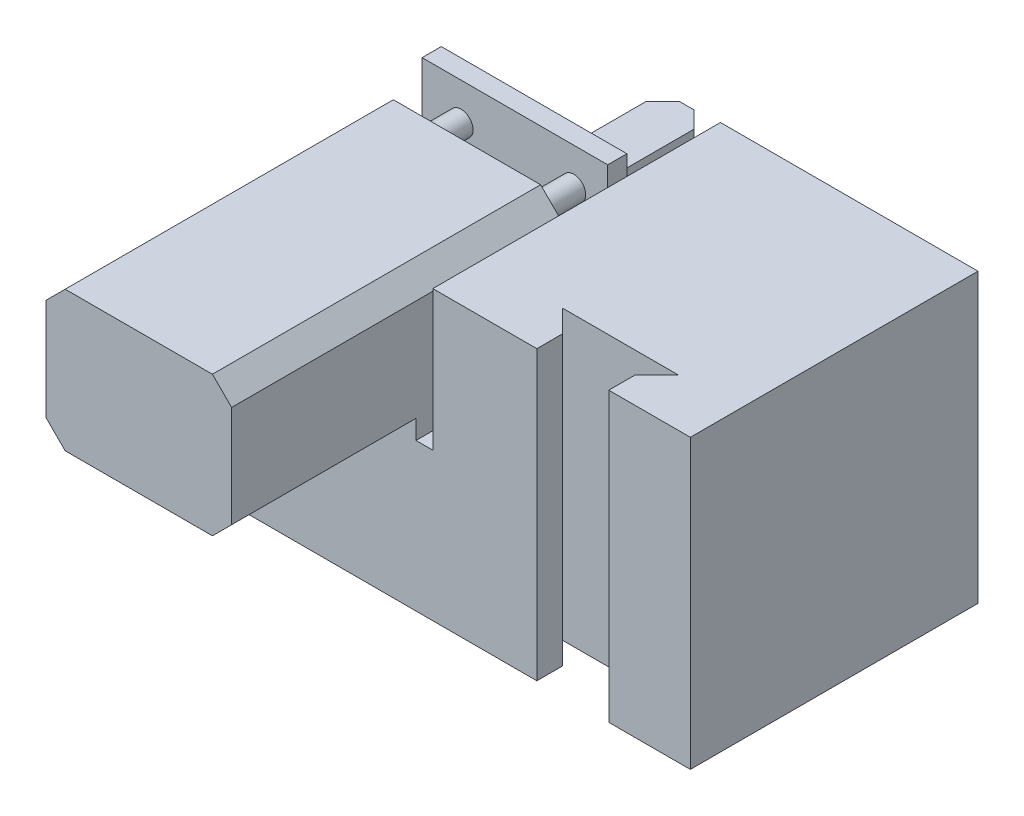
from build123d import *

# Parameters (mm, degrees)
SKETCH1_W           = 127
SKETCH1_H           = 76.2
BOSS_EXTRUDE1_DEPTH = 76.2
CUT_EXTRUDE1_DEPTH  = 77.2
SKETCH3_W           = 58.776435242
SKETCH3_H           = 37.074512471
CUT_EXTRUDE2_DEPTH  = 77.2
SKETCH4_W           = 49.167351348
SKETCH4_H           = 86.931479723
BOSS_EXTRUDE3_DEPTH = 37.074512
CHAMFER1_SIZE       = 5.08
SKETCH5_R           = 3.175
BOSS_EXTRUDE4_DEPTH = 12.7
SKETCH6_W           = 49.167351348
SKETCH6_H           = 37.84167341
BOSS_EXTRUDE5_DEPTH = 5.08
SKETCH7_W           = 12.7
SKETCH7_H           = 3.957251341
BOSS_EXTRUDE6_DEPTH = 50.8
CHAMFER2_SIZE       = 4.445


with BuildPart() as part:
    # Sketch1 → Boss-Extrude1 (new body)
    with BuildSketch(Plane(origin=(0, 0, 0), x_dir=(1, 0, 0), z_dir=(0, 1, 0))):
        with Locations((63.5, 38.1)):
            Rectangle(SKETCH1_W, SKETCH1_H)
    extrude(amount=BOSS_EXTRUDE1_DEPTH)

    # Sketch2 → Cut-Extrude1 (cut, through all)
    with BuildSketch(Plane(origin=(0, 76.2, 0), x_dir=(1, 0, 0), z_dir=(0, 1, 0))):
        Polygon((86.341048303, 0), (105.391048303, 0), (105.391048303, 6.858), (111.233048303, 12.7), (80.499048303, 12.7), (86.341048303, 6.858), align=None)
    extrude(amount=-CUT_EXTRUDE1_DEPTH, mode=Mode.SUBTRACT)

    # Sketch3 → Cut-Extrude2 (cut, through all)
    with BuildSketch(Plane(origin=(0, 0, -76.2), x_dir=(-1, 0, 0), z_dir=(0, 0, -1))):
        with Locations((-29.388217621, 57.662743765)):
            Rectangle(SKETCH3_W, SKETCH3_H)
    extrude(amount=-CUT_EXTRUDE2_DEPTH, mode=Mode.SUBTRACT)

    # Sketch4 → Boss-Extrude3 (add)
    with BuildSketch(Plane(origin=(0, 39.125487529, 0), x_dir=(1, 0, 0), z_dir=(0, 1, 0))):
        with Locations((29.732558923, -5.365739861)):
            Rectangle(SKETCH4_W, SKETCH4_H)
    extrude(amount=BOSS_EXTRUDE3_DEPTH)

    # Chamfer1
    chamfer1_edges = [part.edges().sort_by_distance(p)[0] for p in [
        (5.148883249, 76.199999529, 5.365739861),
        (5.148883249, 39.125487529, 24.415739861),
        (54.316234597, 76.199999529, 5.365739861),
        (54.316234597, 39.125487529, 24.415739861),
    ]]
    chamfer(chamfer1_edges, length=CHAMFER1_SIZE)

    # Sketch5 → Boss-Extrude4 (add)
    with BuildSketch(Plane(origin=(0, 0, -38.1), x_dir=(-1, 0, 0), z_dir=(0, 0, -1))):
        with Locations((-45.312372158, 67.135265035)):
            Circle(SKETCH5_R)
        with Locations((-15.471955986, 67.135265035)):
            Circle(SKETCH5_R)
        with Locations((-45.312372158, 45.448629278)):
            Circle(SKETCH5_R)
        with Locations((-15.471955986, 45.448629278)):
            Circle(SKETCH5_R)
    extrude(amount=BOSS_EXTRUDE4_DEPTH)

    # Sketch6 → Boss-Extrude5 (add)
    with BuildSketch(Plane(origin=(0, 0, -50.8), x_dir=(-1, 0, 0), z_dir=(0, 0, -1))):
        with Locations((-29.732558923, 58.046324234)):
            Rectangle(SKETCH6_W, SKETCH6_H)
    extrude(amount=BOSS_EXTRUDE5_DEPTH)

    # Sketch7 → Boss-Extrude6 (add)
    with BuildSketch(Plane(origin=(0, 0, -55.88), x_dir=(-1, 0, 0), z_dir=(0, 0, -1))):
        with Locations((-40.016034597, 43.1361132)):
            Rectangle(SKETCH7_W, SKETCH7_H)
        with Locations((-19.365834597, 43.1361132)):
            Rectangle(SKETCH7_W, SKETCH7_H)
    extrude(amount=BOSS_EXTRUDE6_DEPTH)

    # Chamfer2
    chamfer2_edges = [part.edges().sort_by_distance(p)[0] for p in [
        (46.366034597, 43.1361132, -106.68),
        (33.666034597, 43.1361132, -106.68),
        (25.715834597, 43.1361132, -106.68),
        (13.015834597, 43.1361132, -106.68),
    ]]
    chamfer(chamfer2_edges, length=CHAMFER2_SIZE)


solid = part.part
